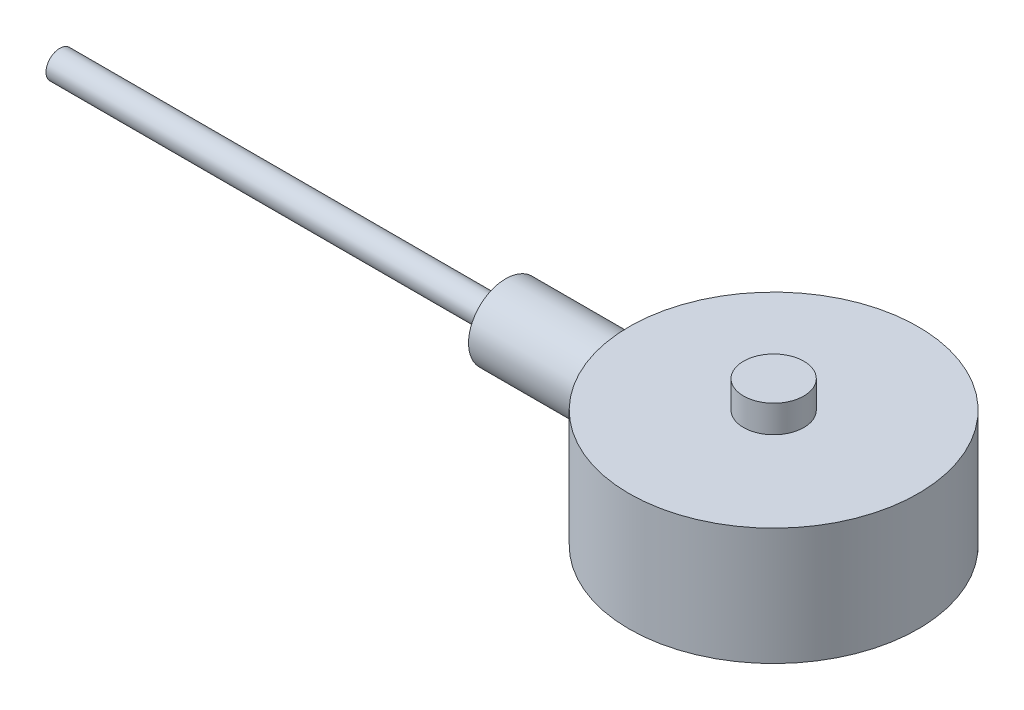
from build123d import *

# Parameters (mm, degrees)
SKETCH1_R                 = 25.4
BASE_DEPTH                = 20.6
SKETCH2_R                 = 5.3
BUTTON_DEPTH              = 4.8
F_5_0MM_DOWEL_HOLE1_D     = 5
F_5_0MM_DOWEL_HOLE1_DEPTH = 10.2
F_5_0MM_DOWEL_HOLE1_TIP   = 1.502151548


with BuildPart() as part:
    # Sketch1 → base (new body)
    with BuildSketch(Plane(origin=(0, 0, 0), x_dir=(1, 0, 0), z_dir=(0, 1, 0))):
        Circle(SKETCH1_R)
    extrude(amount=BASE_DEPTH)

    # Sketch2 → button (add)
    with BuildSketch(Plane(origin=(0, 20.6, 0), x_dir=(1, 0, 0), z_dir=(0, 1, 0))):
        Circle(SKETCH2_R)
    extrude(amount=BUTTON_DEPTH)

    # Sketch3 → cable (revolve)
    with BuildSketch(Plane.XY):
        Polygon((-25.075504061, 10.527856927), (-125.419033552, 10.527856927), (-125.419033552, 12.943392514), (-47.075504061, 12.943392514), (-47.075504061, 17.060710463), (-25.075504061, 17.060710463), (-19.522492217, 17.060710463), (-19.522492217, 10.527856927), align=None)
    revolve(axis=Axis((-25.075504061, 10.527856927, 0), (-1, 0, 0)))

    # Ø5.0mm Dowel Hole1
    with Locations(Plane(origin=(-19.771021996, 0, 8.189425453), x_dir=(0, 0, -1), z_dir=(0, -1, 0))):
        with Locations((0, 0), (-11.581596543, 11.581596543), (-11.581596543, 27.960447449), (0, 39.542043992), (16.378850906, 39.542043992), (27.960447449, 27.960447449), (27.960447449, 11.581596543), (16.378850906, 0)):
            Hole(F_5_0MM_DOWEL_HOLE1_D / 2, depth=F_5_0MM_DOWEL_HOLE1_DEPTH)
            with Locations((0, 0, -(F_5_0MM_DOWEL_HOLE1_DEPTH + F_5_0MM_DOWEL_HOLE1_TIP / 2))):  # 118° drill point
                Cone(0, F_5_0MM_DOWEL_HOLE1_D / 2, F_5_0MM_DOWEL_HOLE1_TIP, mode=Mode.SUBTRACT)


solid = part.part
